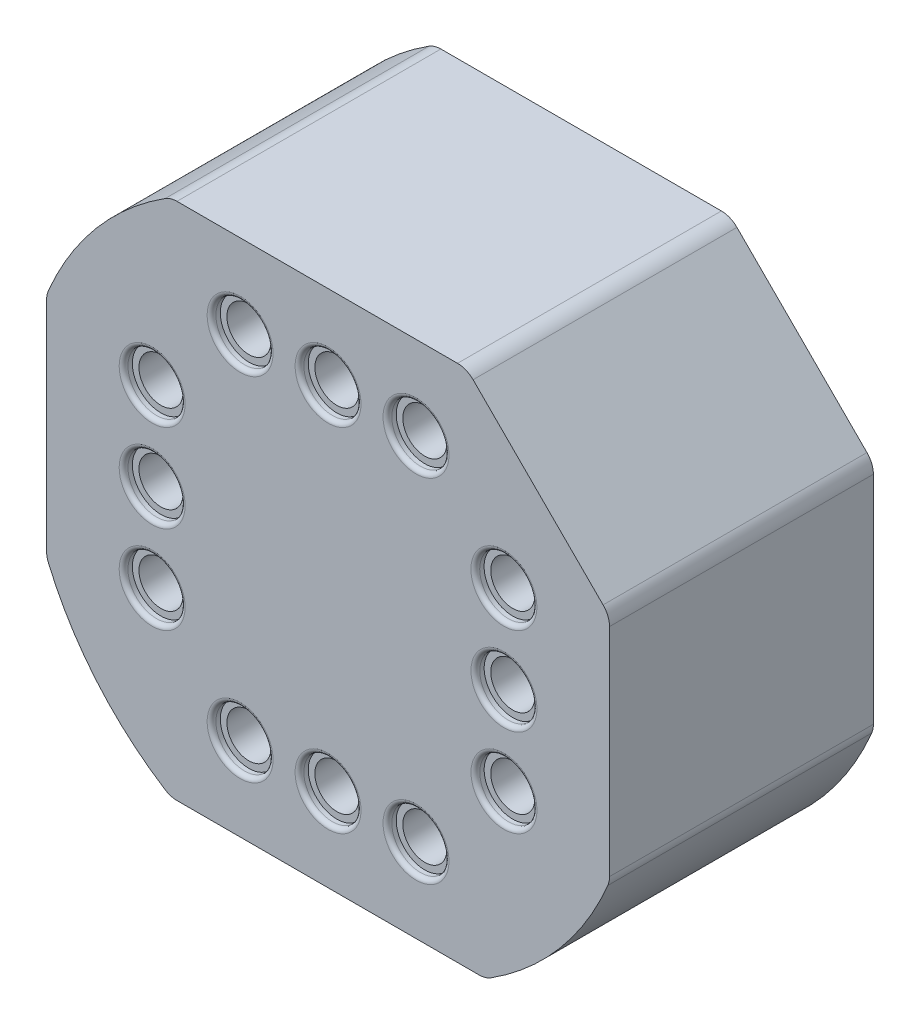
from build123d import *

# Parameters (mm, degrees)
SKETCH1_R           = 0.635
BOSS_EXTRUDE1_DEPTH = 7.62
FILLET1_R           = 0.635
SKETCH2_R           = 0.8255
CUT_EXTRUDE1_DEPTH  = 0.254
FILLET3_R           = 0.127
CHAMFER1_SIZE       = 0.3302
FILLET5_R           = 0.254


with BuildPart() as part:
    # Sketch1 → Boss-Extrude1 (new body)
    with BuildSketch(Plane.XY):
        with BuildLine():
            Line((4.001727835, 7.493), (8.128, 3.366727835))
            Line((8.128, 3.366727835), (8.128, -3.275024427))
            ThreePointArc((8.128, -3.275024427), (6.677631479, -5.674452117), (4.54369013, -7.493))
            Line((4.54369013, -7.493), (-4.54369013, -7.493))
            ThreePointArc((-4.54369013, -7.493), (-6.677631479, -5.674452117), (-8.128, -3.275024427))
            Line((-8.128, -3.275024427), (-8.128, 3.275024427))
            ThreePointArc((-8.128, 3.275024427), (-6.677631479, 5.674452117), (-4.54369013, 7.493))
            Line((-4.54369013, 7.493), (4.001727835, 7.493))
        make_face()
        with Locations((0, 5.08)):
            Circle(SKETCH1_R, mode=Mode.SUBTRACT)
        with Locations((-5.08, 2.54)):
            Circle(SKETCH1_R, mode=Mode.SUBTRACT)
        with Locations((5.08, 2.54)):
            Circle(SKETCH1_R, mode=Mode.SUBTRACT)
        with Locations((-2.54, 5.08)):
            Circle(SKETCH1_R, mode=Mode.SUBTRACT)
        with Locations((2.54, 5.08)):
            Circle(SKETCH1_R, mode=Mode.SUBTRACT)
        with Locations((-5.08, 0)):
            Circle(SKETCH1_R, mode=Mode.SUBTRACT)
        with Locations((-5.08, -2.54)):
            Circle(SKETCH1_R, mode=Mode.SUBTRACT)
        with Locations((-2.54, -5.08)):
            Circle(SKETCH1_R, mode=Mode.SUBTRACT)
        with Locations((0, -5.08)):
            Circle(SKETCH1_R, mode=Mode.SUBTRACT)
        with Locations((2.54, -5.08)):
            Circle(SKETCH1_R, mode=Mode.SUBTRACT)
        with Locations((5.08, -2.54)):
            Circle(SKETCH1_R, mode=Mode.SUBTRACT)
        with Locations((5.08, 0)):
            Circle(SKETCH1_R, mode=Mode.SUBTRACT)
    extrude(amount=BOSS_EXTRUDE1_DEPTH)

    # Fillet1
    fillet1_edges = [part.edges().sort_by_distance(p)[0] for p in [
        (-4.54369013, 7.493, 3.81),
        (4.001727835, 7.493, 3.81),
        (8.128, 3.366727835, 3.81),
        (8.128, -3.275024427, 3.81),
        (4.54369013, -7.493, 3.81),
        (-4.54369013, -7.493, 3.81),
        (-8.128, -3.275024427, 3.81),
        (-8.128, 3.275024427, 3.81),
    ]]
    fillet(fillet1_edges, radius=FILLET1_R)

    # Sketch2 → Cut-Extrude1 (cut)
    with BuildSketch(Plane.XY.offset(7.62)):
        with Locations((0, 5.08)):
            Circle(SKETCH2_R)
        with Locations((5.08, -2.54)):
            Circle(SKETCH2_R)
        with Locations((-2.54, 5.08)):
            Circle(SKETCH2_R)
        with Locations((-5.08, 2.54)):
            Circle(SKETCH2_R)
        with Locations((-5.08, 0)):
            Circle(SKETCH2_R)
        with Locations((-5.08, -2.54)):
            Circle(SKETCH2_R)
        with Locations((-2.54, -5.08)):
            Circle(SKETCH2_R)
        with Locations((0, -5.08)):
            Circle(SKETCH2_R)
        with Locations((2.54, -5.08)):
            Circle(SKETCH2_R)
        with Locations((5.08, 0)):
            Circle(SKETCH2_R)
        with Locations((5.077391464, 2.538695732)):
            Circle(SKETCH2_R)
        with Locations((2.54, 5.08)):
            Circle(SKETCH2_R)
    extrude(amount=-CUT_EXTRUDE1_DEPTH, mode=Mode.SUBTRACT)

    # Fillet3
    fillet3_edges = [part.edges().sort_by_distance(p)[0] for p in [
        (-3.3655, 5.08, 7.62),
        (4.2545, -2.54, 7.62),
        (-0.8255, 5.08, 7.62),
        (1.7145, 5.08, 7.62),
        (4.251891464, 2.538695732, 7.62),
        (4.2545, 0, 7.62),
        (1.7145, -5.08, 7.62),
        (-0.8255, -5.08, 7.62),
        (-3.3655, -5.08, 7.62),
        (-5.9055, -2.54, 7.62),
        (-5.9055, 0, 7.62),
        (-5.9055, 2.54, 7.62),
    ]]
    fillet(fillet3_edges, radius=FILLET3_R)

    # Chamfer1
    chamfer1_edges = [part.edges().sort_by_distance(p)[0] for p in [
        (-3.175, 5.08, 0),
        (-0.635, 5.08, 0),
        (-5.715, 2.54, 0),
        (4.445, 2.54, 0),
        (1.905, 5.08, 0),
        (-5.715, 0, 0),
        (-5.715, -2.54, 0),
        (-3.175, -5.08, 0),
        (-0.635, -5.08, 0),
        (1.905, -5.08, 0),
        (4.445, -2.54, 0),
        (4.445, 0, 0),
    ]]
    chamfer(chamfer1_edges, length=CHAMFER1_SIZE)

    # Fillet5
    fillet5_edges = [part.edges().sort_by_distance(p)[0] for p in [
        (4.445, 0, 0.3302),
        (4.445, -2.54, 0.3302),
        (1.905, -5.08, 0.3302),
        (-0.635, -5.08, 0.3302),
        (-3.175, -5.08, 0.3302),
        (-5.715, -2.54, 0.3302),
        (-5.715, 0, 0.3302),
        (-3.175, 5.08, 0.3302),
        (1.905, 5.08, 0.3302),
        (-5.715, 2.54, 0.3302),
        (4.445, 2.54, 0.3302),
        (-0.635, 5.08, 0.3302),
    ]]
    fillet(fillet5_edges, radius=FILLET5_R)


solid = part.part
